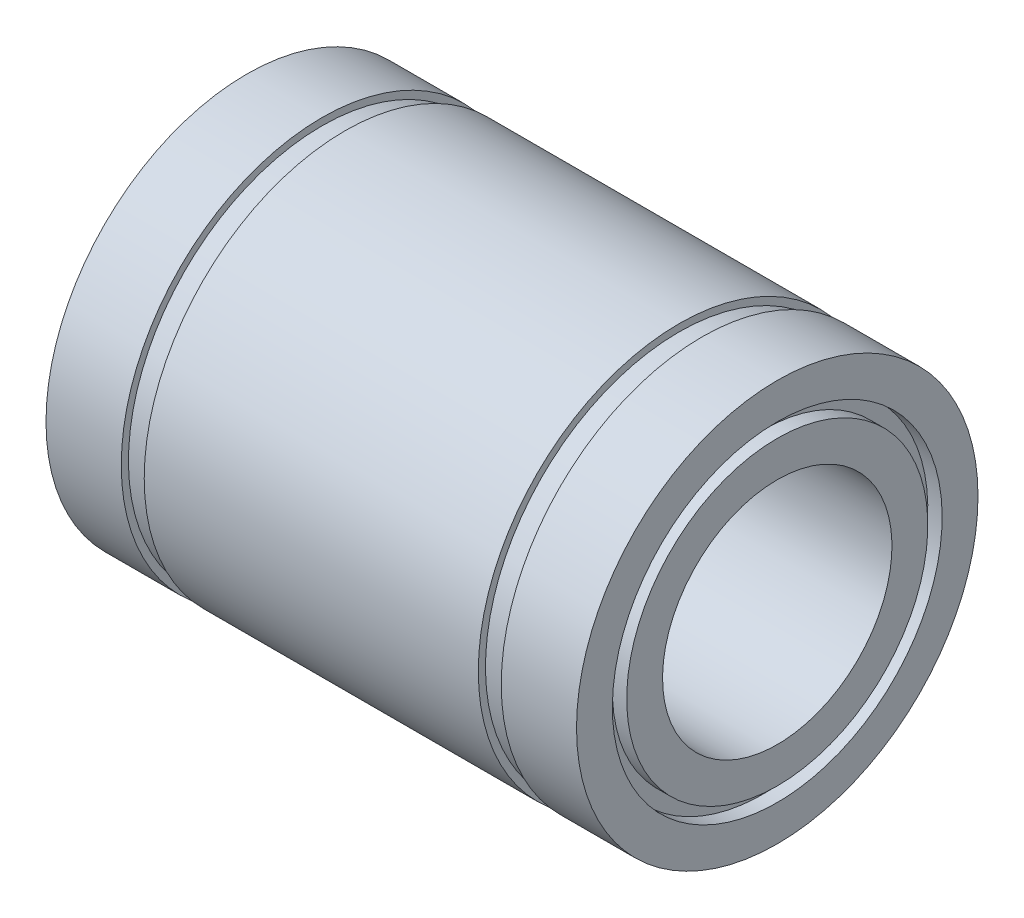
from build123d import *


with BuildPart() as part:
    # Esboço1 → Revolução1 (revolve)
    with BuildSketch(Plane.XY):
        Polygon((-18.5, 14), (-13.25, 14), (-13.25, 13.5), (-11.65, 13.5), (-11.65, 14), (11.65, 14), (11.65, 13.5), (13.25, 13.5), (13.25, 14), (18.5, 14), (18.5, 11.5), (17.5, 11.5), (17.5, 10.5), (18.5, 10.5), (18.5, 8), (-18.5, 8), (-18.5, 10.5), (-17.5, 10.5), (-17.5, 11.5), (-18.5, 11.5), align=None)
    revolve(axis=Axis((0, 0, 0), (-1, 0, 0)))


solid = part.part
